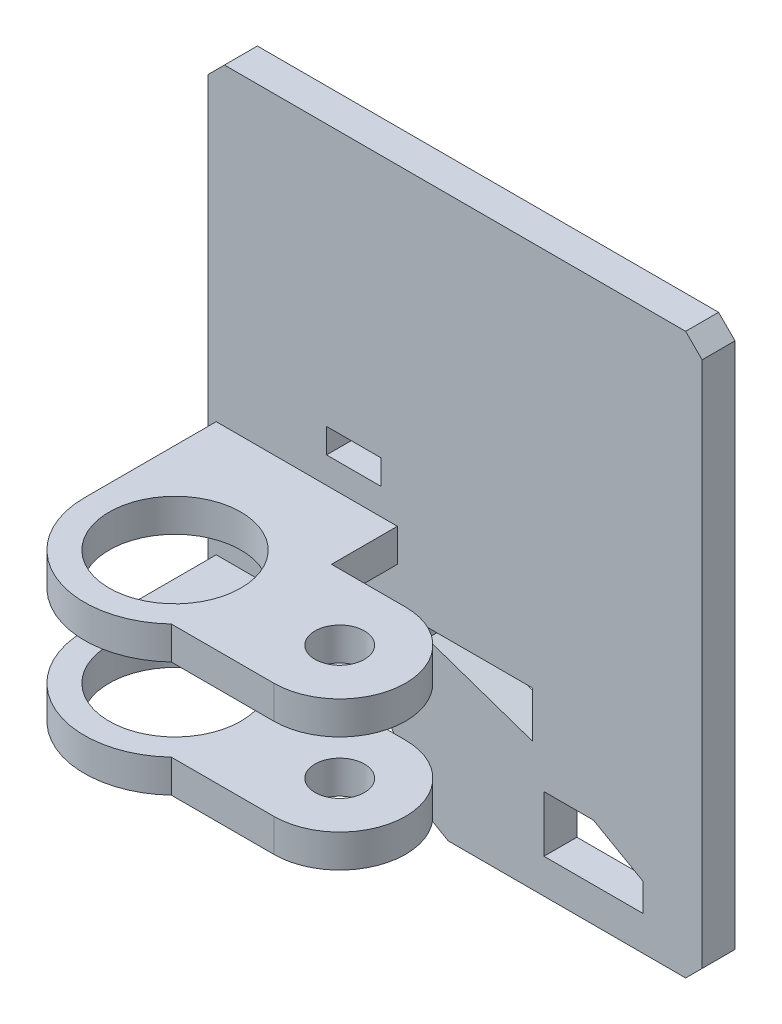
from build123d import *

# Parameters (mm, degrees)
SKETCH2_W           = 33
SKETCH2_H           = 15
BOSS_EXTRUDE1_DEPTH = 20
SKETCH7_R           = 40
SKETCH7_R_2         = 15
BOSS_EXTRUDE5_DEPTH = 20
LPATTERN2_COUNT     = 2
LPATTERN2_PITCH     = 70


with BuildPart() as part:
    # Sketch2 → Boss-Extrude1 (new body)
    with BuildSketch(Plane.XY):
        Polygon((-140, -110), (-48.782097787, -110), (-19.141081636, -161.339745962), (-4.141081636, -170), (140, -170), (150, -160), (150, 160), (140, 170), (-140, 170), (-150, 160), (-150, -100), align=None)
        Polygon((84, -115), (114, -132), (114, -149), (54, -149), (54, -115), align=None, mode=Mode.SUBTRACT)
        Polygon((47, -92), (-17, -70), (-17, -64), (47, -64), align=None, mode=Mode.SUBTRACT)
        with Locations((-61.5, 3.5)):
            Rectangle(SKETCH2_W, SKETCH2_H, mode=Mode.SUBTRACT)
    extrude(amount=BOSS_EXTRUDE1_DEPTH)

    # Sketch7 → Boss-Extrude5 (add)
    with BuildSketch(Plane.XZ.offset(110)):
        with BuildLine():
            Line((-145, 20), (-145, 100))
            ThreePointArc((-145, 100), (-111.780674121, 150.503487353), (-52.250827824, 140))
            Line((-52.250827824, 140), (10, 140))
            ThreePointArc((10, 140), (50, 100), (10, 60))
            Line((10, 60), (-35, 60))
            Line((-35, 60), (-35, 20))
            Line((-35, 20), (-145, 20))
        make_face()
        with Locations((-90, 100)):
            Circle(SKETCH7_R, mode=Mode.SUBTRACT)
        with Locations((10, 100)):
            Circle(SKETCH7_R_2, mode=Mode.SUBTRACT)
    boss_extrude5 = extrude(amount=-BOSS_EXTRUDE5_DEPTH)

    # LPattern2: Boss-Extrude5 ×2
    with Locations(*[(0, i * LPATTERN2_PITCH, 0) for i in range(1, LPATTERN2_COUNT)]):
        add(boss_extrude5)


solid = part.part
